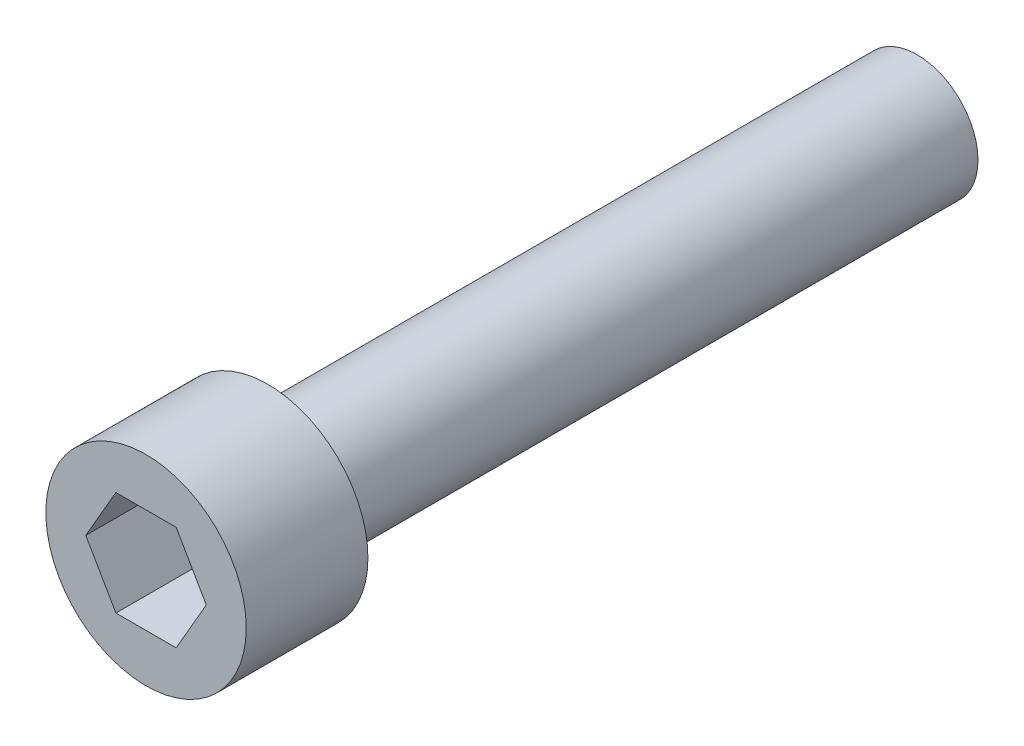
from build123d import *

# Parameters (mm, degrees)
F_9_64_ALLEN_DEPTH = 3.175


with BuildPart() as part:
    # Sketch1 → Revolve1 (revolve)
    with BuildSketch(Plane(origin=(0, 0, 0), x_dir=(1, 0, 0), z_dir=(0, 1, 0))):
        Polygon((0, 0), (0, 26.3906), (2.0828, 26.3906), (2.0828, 4.1656), (3.429, 4.1656), (3.429, 0), align=None)
    revolve(axis=Axis((0, 0, 0), (0, 0, -1)))

    # Sketch2 → 9-64 allen (cut)
    with BuildSketch(Plane.XY):
        Polygon((2.062222993, 0), (1.031111496, 1.7859375), (-1.031111496, 1.7859375), (-2.062222993, 0), (-1.031111496, -1.7859375), (1.031111496, -1.7859375), align=None)
    extrude(amount=-F_9_64_ALLEN_DEPTH, mode=Mode.SUBTRACT)


solid = part.part
